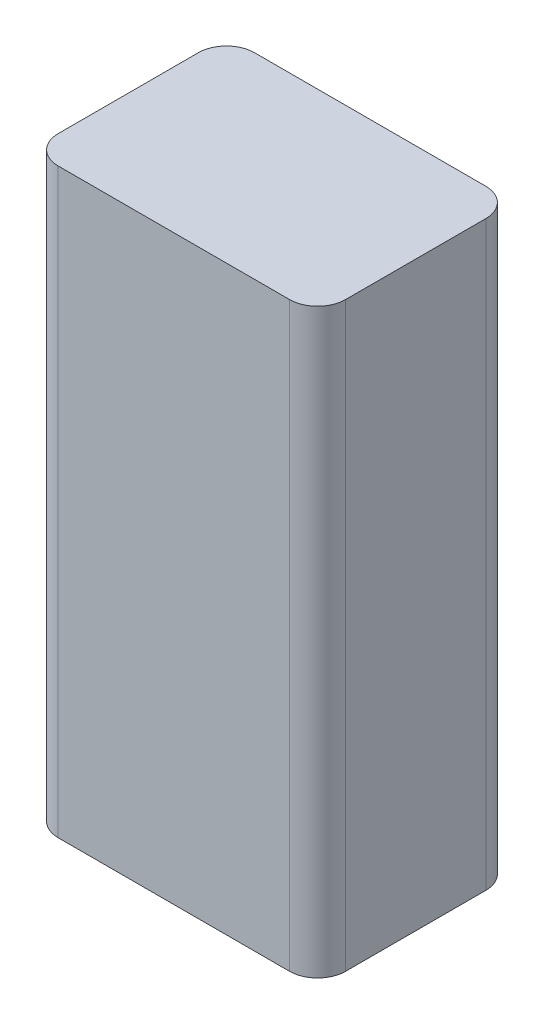
from build123d import *

# Parameters (mm, degrees)
SKETCH1_W           = 26.035
SKETCH1_H           = 52.705
BOSS_EXTRUDE1_DEPTH = 17.78
FILLET1_R           = 2.54


with BuildPart() as part:
    # Sketch1 → Boss-Extrude1 (new body)
    with BuildSketch(Plane.XY):
        with Locations((13.0175, -26.3525)):
            Rectangle(SKETCH1_W, SKETCH1_H)
    extrude(amount=BOSS_EXTRUDE1_DEPTH)

    # Fillet1
    fillet1_edges = [part.edges().sort_by_distance(p)[0] for p in [
        (26.035, -26.3525, 17.78),
        (0, -26.3525, 17.78),
        (26.035, -26.3525, 0),
        (0, -26.3525, 0),
    ]]
    fillet(fillet1_edges, radius=FILLET1_R)


solid = part.part
